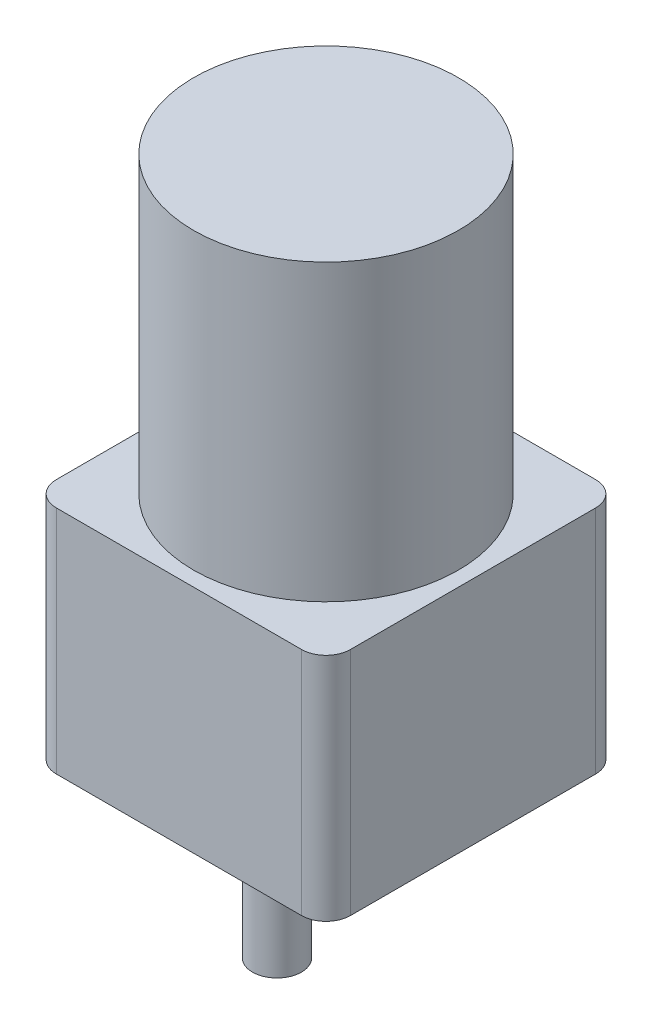
from build123d import *

# Parameters (mm, degrees)
SKETCH1_W           = 60
SKETCH1_H           = 60
BOSS_EXTRUDE1_DEPTH = 47
FILLET1_R           = 5
SKETCH2_R           = 27
BOSS_EXTRUDE2_DEPTH = 60
SKETCH3_R           = 5
BOSS_EXTRUDE3_DEPTH = 30


with BuildPart() as part:
    # Sketch1 → Boss-Extrude1 (new body)
    with BuildSketch(Plane(origin=(0, 0, 0), x_dir=(1, 0, 0), z_dir=(0, 1, 0))):
        Rectangle(SKETCH1_W, SKETCH1_H)
    extrude(amount=BOSS_EXTRUDE1_DEPTH)

    # Fillet1
    fillet1_edges = [part.edges().sort_by_distance(p)[0] for p in [
        (30, 23.5, 30),
        (-30, 23.5, 30),
        (-30, 23.5, -30),
        (30, 23.5, -30),
    ]]
    fillet(fillet1_edges, radius=FILLET1_R)

    # Sketch2 → Boss-Extrude2 (add)
    with BuildSketch(Plane(origin=(0, 47, 0), x_dir=(1, 0, 0), z_dir=(0, 1, 0))):
        Circle(SKETCH2_R)
    extrude(amount=BOSS_EXTRUDE2_DEPTH)

    # Sketch3 → Boss-Extrude3 (add)
    with BuildSketch(Plane.XZ):
        with Locations((0, 10)):
            Circle(SKETCH3_R)
    extrude(amount=BOSS_EXTRUDE3_DEPTH)


solid = part.part
